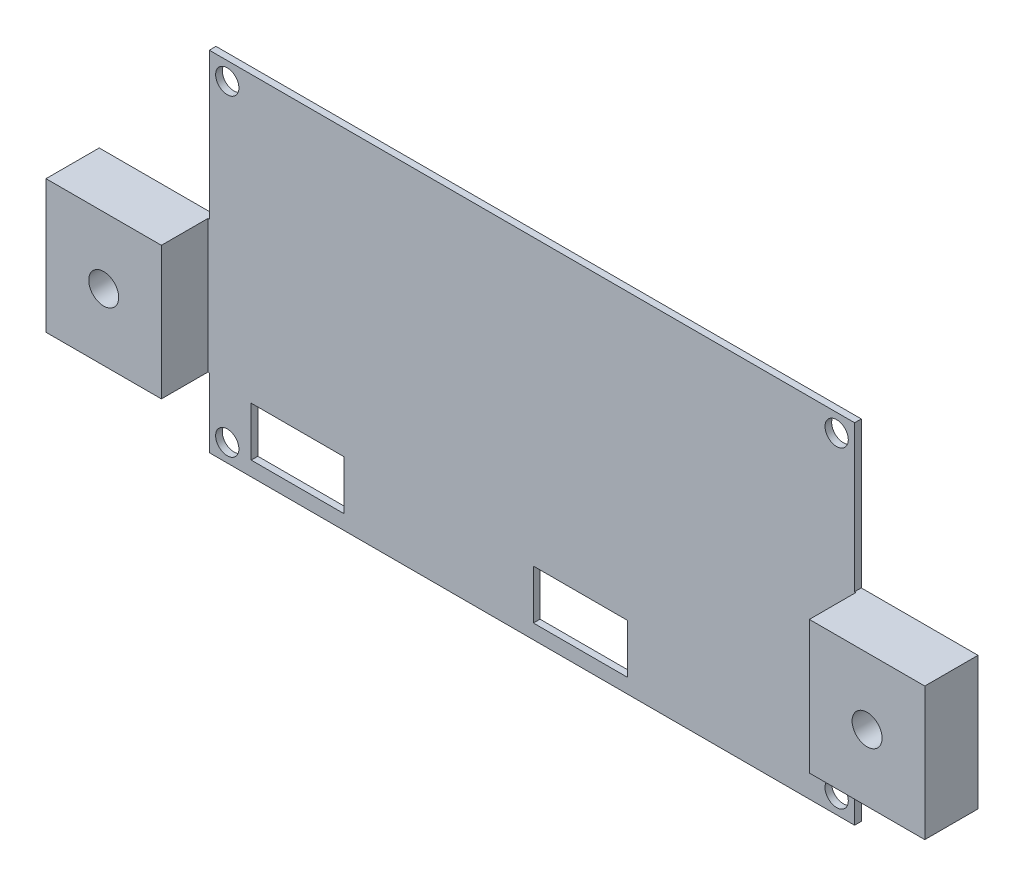
from build123d import *

# Parameters (mm, degrees)
SKIZZE1_R                       = 1.75
SKIZZE1_W                       = 13.916164063
SKIZZE1_H                       = 7.413667428
SKIZZE1_W_2                     = 14.158947343
AUFSATZ_LINEAR_AUSTRAGEN1_DEPTH = 1
SKIZZE2_W                       = 17.347708731
SKIZZE2_H                       = 20
AUFSATZ_LINEAR_AUSTRAGEN2_DEPTH = 7
SKIZZE3_R                       = 2.25
SCHNITT_LINEAR_AUSTRAGEN1_DEPTH = 9


with BuildPart() as part:
    # Skizze1 → Aufsatz-Linear austragen1 (new body)
    with BuildSketch(Plane.XY):
        Polygon((0, 0), (97, 0), (97, 10.4), (114.547708731, 10.4), (114.547708731, 30.4), (97, 30.4), (97, 52.4), (0, 52.4), (0, 30.4), (-17.547708731, 30.4), (-17.547708731, 10.4), (0, 10.4), align=None)
        with Locations((94.3, 49.7)):
            Circle(SKIZZE1_R, mode=Mode.SUBTRACT)
        with Locations((94.3, 2.7)):
            Circle(SKIZZE1_R, mode=Mode.SUBTRACT)
        with Locations((2.7, 2.7)):
            Circle(SKIZZE1_R, mode=Mode.SUBTRACT)
        with Locations((2.7, 49.7)):
            Circle(SKIZZE1_R, mode=Mode.SUBTRACT)
        with Locations((13.256540885, 5.892760701)):
            Rectangle(SKIZZE1_W, SKIZZE1_H, mode=Mode.SUBTRACT)
        with Locations((55.796081341, 5.892760701)):
            Rectangle(SKIZZE1_W_2, SKIZZE1_H, mode=Mode.SUBTRACT)
    extrude(amount=AUFSATZ_LINEAR_AUSTRAGEN1_DEPTH)

    # Skizze2 → Aufsatz-Linear austragen2 (add)
    with BuildSketch(Plane.XY.offset(1)):
        with Locations((-8.873854365, 20.4)):
            Rectangle(SKIZZE2_W, SKIZZE2_H)
        with Locations((105.873854365, 20.4)):
            Rectangle(SKIZZE2_W, SKIZZE2_H)
    extrude(amount=AUFSATZ_LINEAR_AUSTRAGEN2_DEPTH)

    # Skizze3 → Schnitt-Linear austragen1 (cut, through all)
    with BuildSketch(Plane.XY.offset(8)):
        with Locations((-8.873854365, 20.4)):
            Circle(SKIZZE3_R)
        with Locations((105.873854365, 20.4)):
            Circle(SKIZZE3_R)
    extrude(amount=-SCHNITT_LINEAR_AUSTRAGEN1_DEPTH, mode=Mode.SUBTRACT)


solid = part.part
